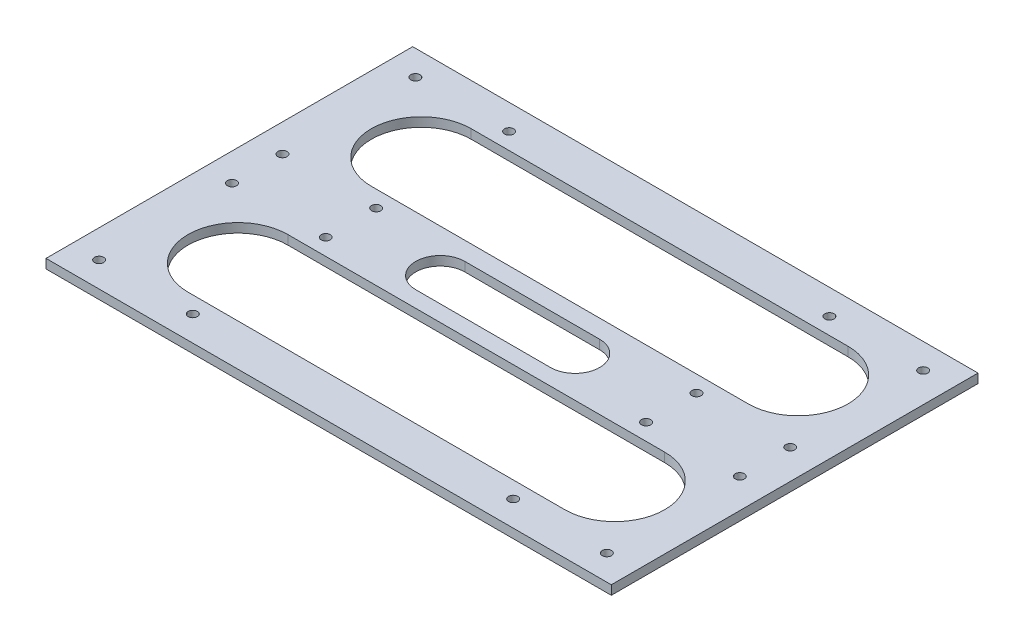
from build123d import *

# Parameters (mm, degrees)
SKETCH1_W           = 185
SKETCH1_H           = 60
BOSS_EXTRUDE1_DEPTH = 3
SKETCH2_R           = 1.5
CUT_EXTRUDE1_DEPTH  = 3
CUT_EXTRUDE2_DEPTH  = 10


with BuildPart() as part:
    # Sketch1 → Boss-Extrude1 (new body)
    with BuildSketch(Plane(origin=(0, 0, 0), x_dir=(1, 0, 0), z_dir=(0, 1, 0))):
        with Locations((-80.280821918, -28.849315068)):
            Rectangle(SKETCH1_W, SKETCH1_H)
    extrude(amount=BOSS_EXTRUDE1_DEPTH)

    # Sketch2 → Cut-Extrude1 (cut)
    with BuildSketch(Plane(origin=(0, 3, 0), x_dir=(1, 0, 0), z_dir=(0, 1, 0))):
        with Locations((-163.653280502, -7.099315068)):
            Circle(SKETCH2_R)
        with Locations((-163.653280502, -50.599315068)):
            Circle(SKETCH2_R)
        with Locations((-28.153280502, -50.599315068)):
            Circle(SKETCH2_R)
        with Locations((-28.153280502, -7.099315068)):
            Circle(SKETCH2_R)
        with Locations((-132.986057559, -7.099315068)):
            Circle(SKETCH2_R)
        with Locations((-132.986057559, -50.599315068)):
            Circle(SKETCH2_R)
        with Locations((2.513942441, -50.599315068)):
            Circle(SKETCH2_R)
        with Locations((2.513942441, -7.099315068)):
            Circle(SKETCH2_R)
        with BuildLine():
            Line((-139.976197673, -12.515770436), (-16.64325173, -12.515770436))
            ThreePointArc((-16.64325173, -12.515770436), (-0.309707097, -28.849315068), (-16.64325173, -45.182859701))
            Line((-16.64325173, -45.182859701), (-139.976197673, -45.182859701))
            ThreePointArc((-139.976197673, -45.182859701), (-156.309742305, -28.849315068), (-139.976197673, -12.515770436))
        make_face()
    extrude(amount=-CUT_EXTRUDE1_DEPTH, mode=Mode.SUBTRACT)

    # Mirror1: part across plane


with BuildPart() as part_1:
    add(part.part)
    add(part.part.mirror(Plane(origin=(-172.780821918, 3, 58.849315068), x_dir=(1, 0, 0), z_dir=(0, 0, -1))))

    # Sketch3 → Cut-Extrude2 (cut)
    with BuildSketch(Plane(origin=(0, 3, 0), x_dir=(1, 0, 0), z_dir=(0, 1, 0))):
        with BuildLine():
            Line((-103.404990518, -51.173645659), (-59.281035157, -51.173645659))
            ThreePointArc((-59.281035157, -51.173645659), (-51.253781089, -59.200899728), (-59.281035157, -67.228153796))
            Line((-59.281035157, -67.228153796), (-103.404990518, -67.228153796))
            ThreePointArc((-103.404990518, -67.228153796), (-111.432244586, -59.200899728), (-103.404990518, -51.173645659))
        make_face()
    extrude(amount=-CUT_EXTRUDE2_DEPTH, mode=Mode.SUBTRACT)


solid = part_1.part
